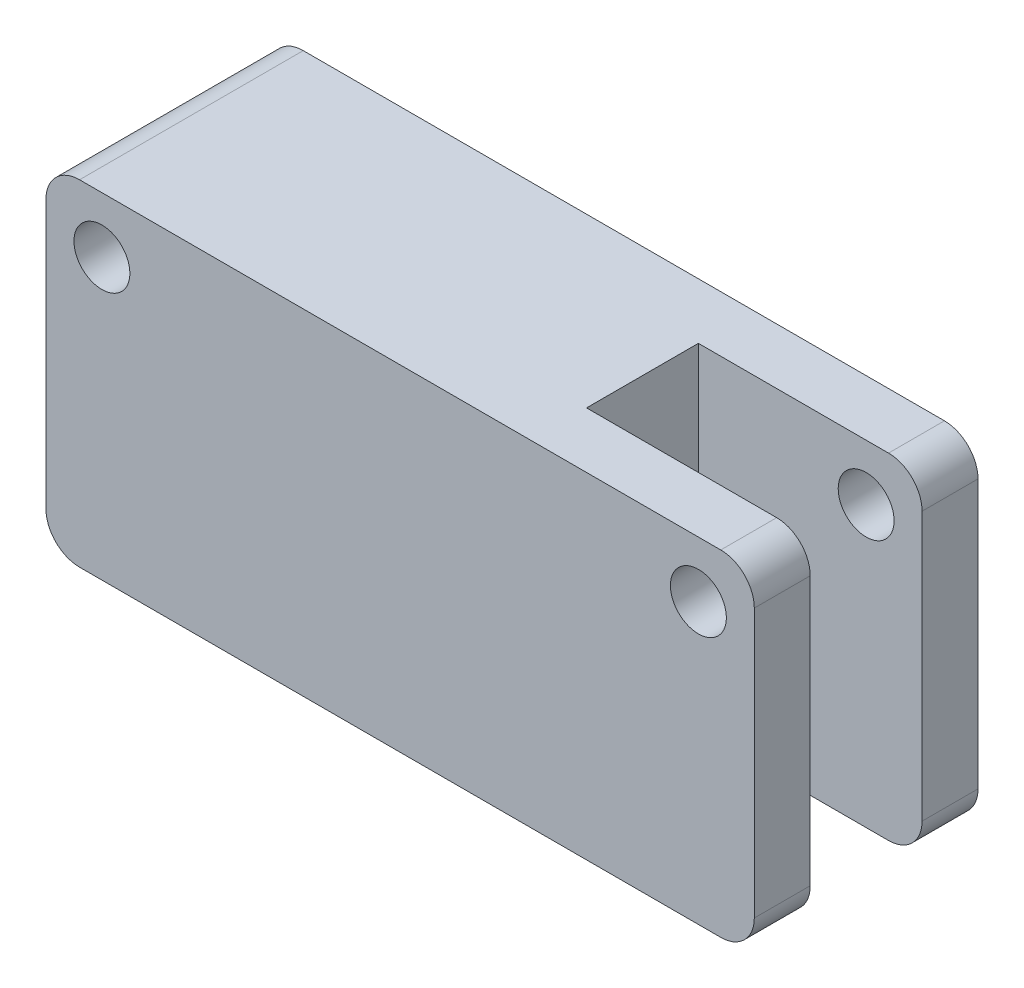
from build123d import *

# Parameters (mm, degrees)
ESQUISSE2_W             = 63.33
ESQUISSE2_H             = 20
BOSS_EXTRU_1_DEPTH      = 15
CONG_1_R                = 3
ESQUISSE4_W             = 20
ESQUISSE4_H             = 10
ENL_V_MAT_EXTRU_1_DEPTH = 71.786219704
ESQUISSE5_R             = 2.5
ENL_V_MAT_EXTRU_2_DEPTH = 69.085893546


with BuildPart() as part:
    # Esquisse2 → Boss.-Extru.1 (new, symmetric)
    with BuildSketch(Plane(origin=(0, 0, 0), x_dir=(1, 0, 0), z_dir=(0, 1, 0))):
        with Locations((31.665, 0)):
            Rectangle(ESQUISSE2_W, ESQUISSE2_H)
    extrude(amount=BOSS_EXTRU_1_DEPTH, both=True)

    # Congé1
    cong_1_edges = [part.edges().sort_by_distance(p)[0] for p in [
        (0, 15, 0),
        (63.33, 15, 0),
        (63.33, -15, 0),
        (0, -15, 0),
    ]]
    fillet(cong_1_edges, radius=CONG_1_R)

    # Esquisse4 → Enlèv. mat.-Extru.1 (cut, through all)
    with BuildSketch(Plane(origin=(0, 15, 0), x_dir=(1, 0, 0), z_dir=(0, 1, 0))):
        with Locations((53.33, 0)):
            Rectangle(ESQUISSE4_W, ESQUISSE4_H)
    extrude(amount=-ENL_V_MAT_EXTRU_1_DEPTH, mode=Mode.SUBTRACT)

    # Esquisse5 → Enlèv. mat.-Extru.2 (cut, through all)
    with BuildSketch(Plane(origin=(0, 0, -10), x_dir=(-1, 0, 0), z_dir=(0, 0, -1))):
        with Locations((-58.33, 10)):
            Circle(ESQUISSE5_R)
        with Locations((-5, 10)):
            Circle(ESQUISSE5_R)
    extrude(amount=-ENL_V_MAT_EXTRU_2_DEPTH, mode=Mode.SUBTRACT)


solid = part.part
